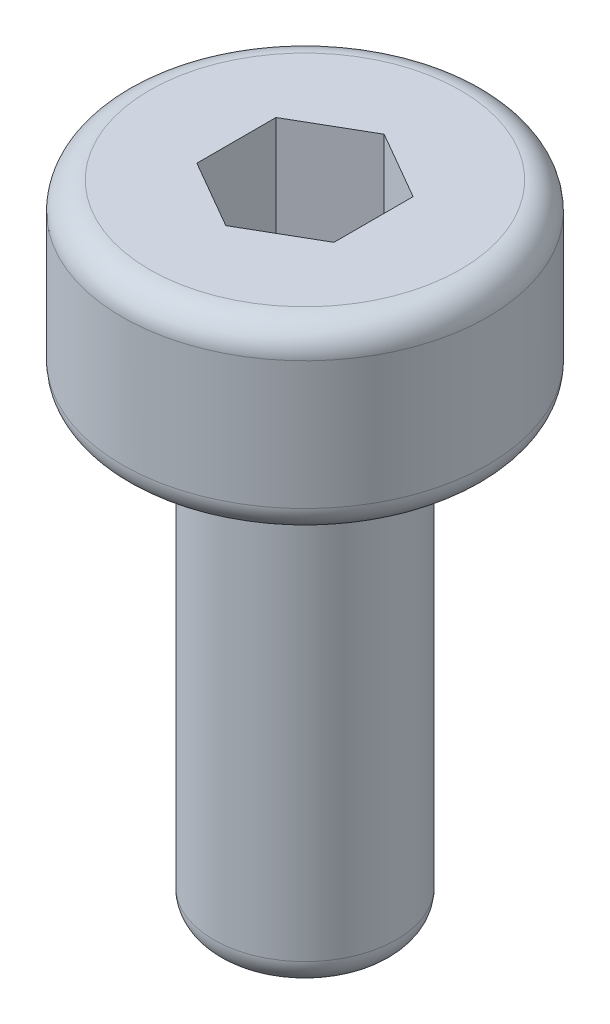
from build123d import *

# Parameters (mm, degrees)
SKETCH_1_W          = 2
SKETCH_1_H          = 2
SKETCH_2_R          = 1
EXTRUDE_1_DEPTH     = 5
CUT_EXTRUDE_1_DEPTH = 1.5
FILLET_1_R          = 0.3


with BuildPart() as part:
    # 草图1 → 旋转1 (revolve)
    with BuildSketch(Plane.XY):
        with Locations((1, -1)):
            Rectangle(SKETCH_1_W, SKETCH_1_H)
    revolve(axis=Axis((0, 0, 0), (0, -1, 0)))

    # 草图2 → 凸台-拉伸1 (add)
    with BuildSketch(Plane.XZ.offset(2)):
        Circle(SKETCH_2_R)
    extrude(amount=EXTRUDE_1_DEPTH)

    # 草图3 → 切除-拉伸1 (cut)
    with BuildSketch(Plane(origin=(0, 0, 0), x_dir=(-1, 0, 0), z_dir=(0, 1, 0))):
        Polygon((0, -0.866025404), (0.75, -0.433012702), (0.75, 0.433012702), (0, 0.866025404), (-0.75, 0.433012702), (-0.75, -0.433012702), align=None)
    extrude(amount=-CUT_EXTRUDE_1_DEPTH, mode=Mode.SUBTRACT)

    # 圆角1
    fillet_1_edges = [part.edges().sort_by_distance(p)[0] for p in [
        (-1, -7, 0),
        (-2, -2, 0),
        (-2, 0, 0),
    ]]
    fillet(fillet_1_edges, radius=FILLET_1_R)


solid = part.part
